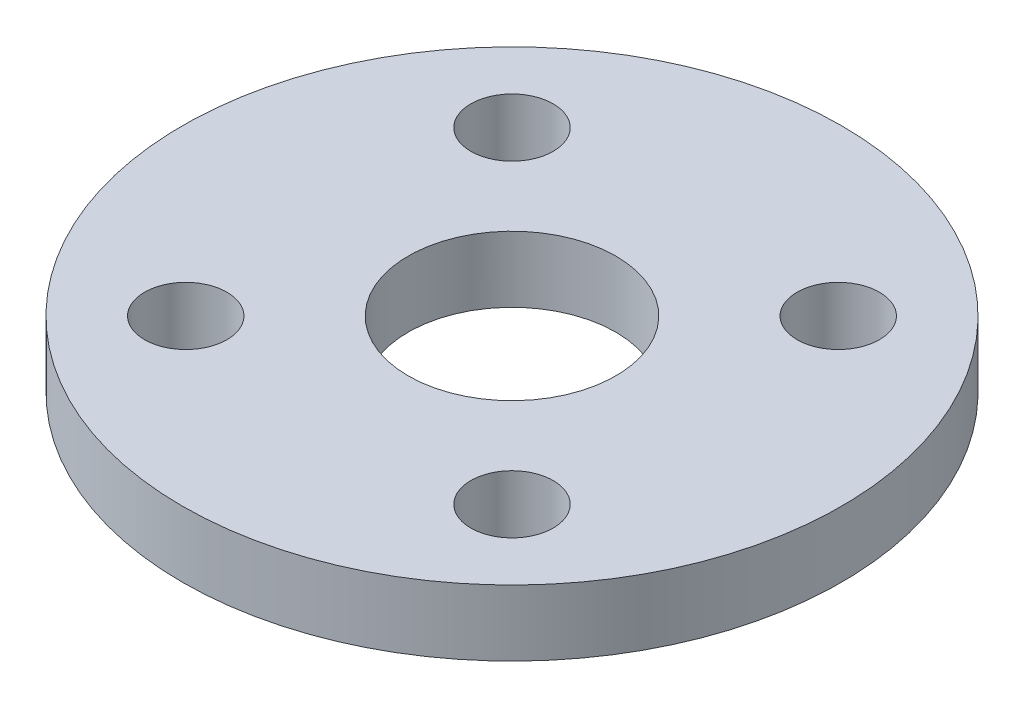
from build123d import *

# Parameters (mm, degrees)
SKETCH_1_W              = 10
SKETCH_1_H              = 2
SKETCH_2_R              = 4.5
EXTRUDE_1_DEPTH         = 2.5
CUT_EXTRUDE_1_DEPTH     = 3.6
HOLE_WIZARD_3_0_3_1_D   = 3
HOLE_WIZARD_2_5_2_5_1_D = 2.5
CHAMFER_1_SIZE          = 0.140560122
CHAMFER_1_EDGE_2_SIZE   = 0.140560122
CHAMFER_1_EDGE_3_SIZE   = 0.140560122
CHAMFER_1_EDGE_4_SIZE   = 0.140560122
CHAMFER_1_EDGE_5_SIZE   = 0.140560122
CHAMFER_1_EDGE_6_SIZE   = 0.140560122
CHAMFER_1_EDGE_7_SIZE   = 0.140560122
CHAMFER_1_EDGE_8_SIZE   = 0.140560122
CHAMFER_1_EDGE_9_SIZE   = 0.140560122
CHAMFER_1_EDGE_10_SIZE  = 0.140560122
CHAMFER_1_EDGE_11_SIZE  = 0.140560122
CHAMFER_1_EDGE_12_SIZE  = 0.140560122
CHAMFER_1_EDGE_13_SIZE  = 0.140560122
CHAMFER_1_EDGE_14_SIZE  = 0.140560122
CHAMFER_1_EDGE_15_SIZE  = 0.140560122
CHAMFER_1_EDGE_16_SIZE  = 0.140560122
CHAMFER_1_EDGE_17_SIZE  = 0.140560122
CHAMFER_1_EDGE_18_SIZE  = 0.140560122
CHAMFER_1_EDGE_19_SIZE  = 0.140560122
CHAMFER_1_EDGE_20_SIZE  = 0.140560122
CHAMFER_1_EDGE_21_SIZE  = 0.140560122
CHAMFER_1_EDGE_22_SIZE  = 0.140560122
CHAMFER_1_EDGE_23_SIZE  = 0.140560122
CHAMFER_1_EDGE_24_SIZE  = 0.140560122
CHAMFER_1_EDGE_25_SIZE  = 0.140560122
CHAMFER_1_EDGE_26_SIZE  = 0.140560122
SKETCH_8_R              = 4.5
CUT_EXTRUDE_2_DEPTH     = 4.5
SKETCH_9_R              = 4.5
SKETCH_9_R_2            = 3.15
EXTRUDE_2_DEPTH         = 2


with BuildPart() as part:
    # Эскиз1 → Повернуть1 (revolve)
    with BuildSketch(Plane.XY, mode=Mode.PRIVATE) as revolve_1_sk:
        with Locations((5, 1)):
            Rectangle(SKETCH_1_W, SKETCH_1_H)
    revolve(revolve_1_sk.sketch.rotate(Axis((0, 2, 0), (0, -1, 0)), 270), axis=Axis((0, 2, 0), (0, -1, 0)))

    # Эскиз2 → Бобышка-Вытянуть1 (add)
    with BuildSketch(Plane(origin=(0, 2, 0), x_dir=(-1, 0, 0), z_dir=(0, 1, 0))):
        with Locations(Location((0, 0, 0), (0, 0, 90))):
            Circle(SKETCH_2_R)
    extrude(amount=EXTRUDE_1_DEPTH)

    # Эскиз3 → Вырез-Вытянуть1 (cut)
    with BuildSketch(Plane(origin=(0, 4.5, 0), x_dir=(-1, 0, 0), z_dir=(0, 1, 0))):
        Polygon((-2.711547104, 1.028354172), (-2.477853855, 0.610736123), (-2.878855735, 0.349556373), (-2.552010646, 0), (-2.878855735, -0.349556373), (-2.477853855, -0.610736123), (-2.711547104, -1.028354172), (-2.259693204, -1.185978483), (-2.386653211, -1.647387766), (-1.910207398, -1.692296084), (-1.923055709, -2.17068117), (-1.449707281, -2.100263587), (-1.347697199, -2.567822474), (-0.904955447, -2.386171406), (-0.694015426, -2.815731271), (-0.307610891, -2.533403615), (0, -2.9), (0.307610891, -2.533403615), (0.694015426, -2.815731271), (0.904955447, -2.386171406), (1.347697199, -2.567822474), (1.449707281, -2.100263587), (1.923055709, -2.17068117), (1.910207398, -1.692296084), (2.386653211, -1.647387766), (2.259693204, -1.185978483), (2.711547104, -1.028354172), (2.477853855, -0.610736123), (2.878855735, -0.349556373), (2.552010646, 0), (2.878855735, 0.349556373), (2.477853855, 0.610736123), (2.711547104, 1.028354172), (2.259693204, 1.185978483), (2.386653211, 1.647387766), (1.910207398, 1.692296084), (1.923055709, 2.17068117), (1.449707281, 2.100263587), (1.347697199, 2.567822474), (0.904955447, 2.386171406), (0.694015426, 2.815731271), (0.307610891, 2.533403615), (0, 2.9), (-0.307610891, 2.533403615), (-0.694015426, 2.815731271), (-0.904955447, 2.386171406), (-1.347697199, 2.567822474), (-1.449707281, 2.100263587), (-1.923055709, 2.17068117), (-1.910207398, 1.692296084), (-2.386653211, 1.647387766), (-2.259693204, 1.185978483), align=None)
    extrude(amount=-CUT_EXTRUDE_1_DEPTH, mode=Mode.SUBTRACT)

    # Диаметр отверстия Ø3.0 (3)1 (through all)
    with Locations(Plane(origin=(0, 0.9, 0), x_dir=(1, 0, 0), z_dir=(0, 1, 0))):
        with Locations((0, 0)):
            Hole(HOLE_WIZARD_3_0_3_1_D / 2)

    # Диаметр отверстия Ø2.5 (2.5)1 (through all)
    with Locations(Plane(origin=(0, 2, 0), x_dir=(1, 0, 0), z_dir=(0, 1, 0))):
        with Locations((-4.949747468, 4.949747468), (4.949747468, 4.949747468), (4.949747468, -4.949747468), (-4.949747468, -4.949747468)):
            Hole(HOLE_WIZARD_2_5_2_5_1_D / 2)

    # Фаска1
    chamfer_1_edges = [part.edges().sort_by_distance(p)[0] for p in [
        (2.259693204, 2.7, 1.185978483),
    ]]
    chamfer(chamfer_1_edges, length=CHAMFER_1_SIZE)

    # Фаска1 edge 2
    chamfer_1_edge_2_edges = [part.edges().sort_by_distance(p)[0] for p in [
        (1.910207398, 2.7, 1.692296084),
    ]]
    chamfer(chamfer_1_edge_2_edges, length=CHAMFER_1_EDGE_2_SIZE)

    # Фаска1 edge 3
    chamfer_1_edge_3_edges = [part.edges().sort_by_distance(p)[0] for p in [
        (1.449707281, 2.7, 2.100263587),
    ]]
    chamfer(chamfer_1_edge_3_edges, length=CHAMFER_1_EDGE_3_SIZE)

    # Фаска1 edge 4
    chamfer_1_edge_4_edges = [part.edges().sort_by_distance(p)[0] for p in [
        (0.904955447, 2.7, 2.386171406),
    ]]
    chamfer(chamfer_1_edge_4_edges, length=CHAMFER_1_EDGE_4_SIZE)

    # Фаска1 edge 5
    chamfer_1_edge_5_edges = [part.edges().sort_by_distance(p)[0] for p in [
        (0.307610891, 2.7, 2.533403615),
    ]]
    chamfer(chamfer_1_edge_5_edges, length=CHAMFER_1_EDGE_5_SIZE)

    # Фаска1 edge 6
    chamfer_1_edge_6_edges = [part.edges().sort_by_distance(p)[0] for p in [
        (-0.307610891, 2.7, 2.533403615),
    ]]
    chamfer(chamfer_1_edge_6_edges, length=CHAMFER_1_EDGE_6_SIZE)

    # Фаска1 edge 7
    chamfer_1_edge_7_edges = [part.edges().sort_by_distance(p)[0] for p in [
        (-0.904955447, 2.7, 2.386171406),
    ]]
    chamfer(chamfer_1_edge_7_edges, length=CHAMFER_1_EDGE_7_SIZE)

    # Фаска1 edge 8
    chamfer_1_edge_8_edges = [part.edges().sort_by_distance(p)[0] for p in [
        (-1.449707281, 2.7, 2.100263587),
    ]]
    chamfer(chamfer_1_edge_8_edges, length=CHAMFER_1_EDGE_8_SIZE)

    # Фаска1 edge 9
    chamfer_1_edge_9_edges = [part.edges().sort_by_distance(p)[0] for p in [
        (-1.910207398, 2.7, 1.692296084),
    ]]
    chamfer(chamfer_1_edge_9_edges, length=CHAMFER_1_EDGE_9_SIZE)

    # Фаска1 edge 10
    chamfer_1_edge_10_edges = [part.edges().sort_by_distance(p)[0] for p in [
        (-2.259693204, 2.7, 1.185978483),
    ]]
    chamfer(chamfer_1_edge_10_edges, length=CHAMFER_1_EDGE_10_SIZE)

    # Фаска1 edge 11
    chamfer_1_edge_11_edges = [part.edges().sort_by_distance(p)[0] for p in [
        (-2.477853855, 2.7, 0.610736123),
    ]]
    chamfer(chamfer_1_edge_11_edges, length=CHAMFER_1_EDGE_11_SIZE)

    # Фаска1 edge 12
    chamfer_1_edge_12_edges = [part.edges().sort_by_distance(p)[0] for p in [
        (-2.552010646, 2.7, 0),
    ]]
    chamfer(chamfer_1_edge_12_edges, length=CHAMFER_1_EDGE_12_SIZE)

    # Фаска1 edge 13
    chamfer_1_edge_13_edges = [part.edges().sort_by_distance(p)[0] for p in [
        (-2.477853855, 2.7, -0.610736123),
    ]]
    chamfer(chamfer_1_edge_13_edges, length=CHAMFER_1_EDGE_13_SIZE)

    # Фаска1 edge 14
    chamfer_1_edge_14_edges = [part.edges().sort_by_distance(p)[0] for p in [
        (-2.259693204, 2.7, -1.185978483),
    ]]
    chamfer(chamfer_1_edge_14_edges, length=CHAMFER_1_EDGE_14_SIZE)

    # Фаска1 edge 15
    chamfer_1_edge_15_edges = [part.edges().sort_by_distance(p)[0] for p in [
        (-1.910207398, 2.7, -1.692296084),
    ]]
    chamfer(chamfer_1_edge_15_edges, length=CHAMFER_1_EDGE_15_SIZE)

    # Фаска1 edge 16
    chamfer_1_edge_16_edges = [part.edges().sort_by_distance(p)[0] for p in [
        (-1.449707281, 2.7, -2.100263587),
    ]]
    chamfer(chamfer_1_edge_16_edges, length=CHAMFER_1_EDGE_16_SIZE)

    # Фаска1 edge 17
    chamfer_1_edge_17_edges = [part.edges().sort_by_distance(p)[0] for p in [
        (-0.904955447, 2.7, -2.386171406),
    ]]
    chamfer(chamfer_1_edge_17_edges, length=CHAMFER_1_EDGE_17_SIZE)

    # Фаска1 edge 18
    chamfer_1_edge_18_edges = [part.edges().sort_by_distance(p)[0] for p in [
        (-0.307610891, 2.7, -2.533403615),
    ]]
    chamfer(chamfer_1_edge_18_edges, length=CHAMFER_1_EDGE_18_SIZE)

    # Фаска1 edge 19
    chamfer_1_edge_19_edges = [part.edges().sort_by_distance(p)[0] for p in [
        (0.307610891, 2.7, -2.533403615),
    ]]
    chamfer(chamfer_1_edge_19_edges, length=CHAMFER_1_EDGE_19_SIZE)

    # Фаска1 edge 20
    chamfer_1_edge_20_edges = [part.edges().sort_by_distance(p)[0] for p in [
        (0.904955447, 2.7, -2.386171406),
    ]]
    chamfer(chamfer_1_edge_20_edges, length=CHAMFER_1_EDGE_20_SIZE)

    # Фаска1 edge 21
    chamfer_1_edge_21_edges = [part.edges().sort_by_distance(p)[0] for p in [
        (1.449707281, 2.7, -2.100263587),
    ]]
    chamfer(chamfer_1_edge_21_edges, length=CHAMFER_1_EDGE_21_SIZE)

    # Фаска1 edge 22
    chamfer_1_edge_22_edges = [part.edges().sort_by_distance(p)[0] for p in [
        (1.910207398, 2.7, -1.692296084),
    ]]
    chamfer(chamfer_1_edge_22_edges, length=CHAMFER_1_EDGE_22_SIZE)

    # Фаска1 edge 23
    chamfer_1_edge_23_edges = [part.edges().sort_by_distance(p)[0] for p in [
        (2.259693204, 2.7, -1.185978483),
    ]]
    chamfer(chamfer_1_edge_23_edges, length=CHAMFER_1_EDGE_23_SIZE)

    # Фаска1 edge 24
    chamfer_1_edge_24_edges = [part.edges().sort_by_distance(p)[0] for p in [
        (2.477853855, 2.7, -0.610736123),
    ]]
    chamfer(chamfer_1_edge_24_edges, length=CHAMFER_1_EDGE_24_SIZE)

    # Фаска1 edge 25
    chamfer_1_edge_25_edges = [part.edges().sort_by_distance(p)[0] for p in [
        (2.552010646, 2.7, 0),
    ]]
    chamfer(chamfer_1_edge_25_edges, length=CHAMFER_1_EDGE_25_SIZE)

    # Фаска1 edge 26
    chamfer_1_edge_26_edges = [part.edges().sort_by_distance(p)[0] for p in [
        (2.477853855, 2.7, 0.610736123),
    ]]
    chamfer(chamfer_1_edge_26_edges, length=CHAMFER_1_EDGE_26_SIZE)

    # Эскиз8 → Вырез-Вытянуть2 (cut)
    with BuildSketch(Plane(origin=(0, 4.5, 0), x_dir=(1, 0, 0), z_dir=(0, 1, 0))):
        with Locations(Location((0, 0, 0), (0, 0, 270))):
            Circle(SKETCH_8_R)
    extrude(amount=-CUT_EXTRUDE_2_DEPTH, mode=Mode.SUBTRACT)

    # Эскиз9 → Бобышка-Вытянуть2 (add)
    with BuildSketch(Plane.XZ):
        Circle(SKETCH_9_R)
        with Locations(Location((0, 0, 0), (0, 0, 270))):
            Circle(SKETCH_9_R_2, mode=Mode.SUBTRACT)
    extrude(amount=-EXTRUDE_2_DEPTH)


solid = part.part
